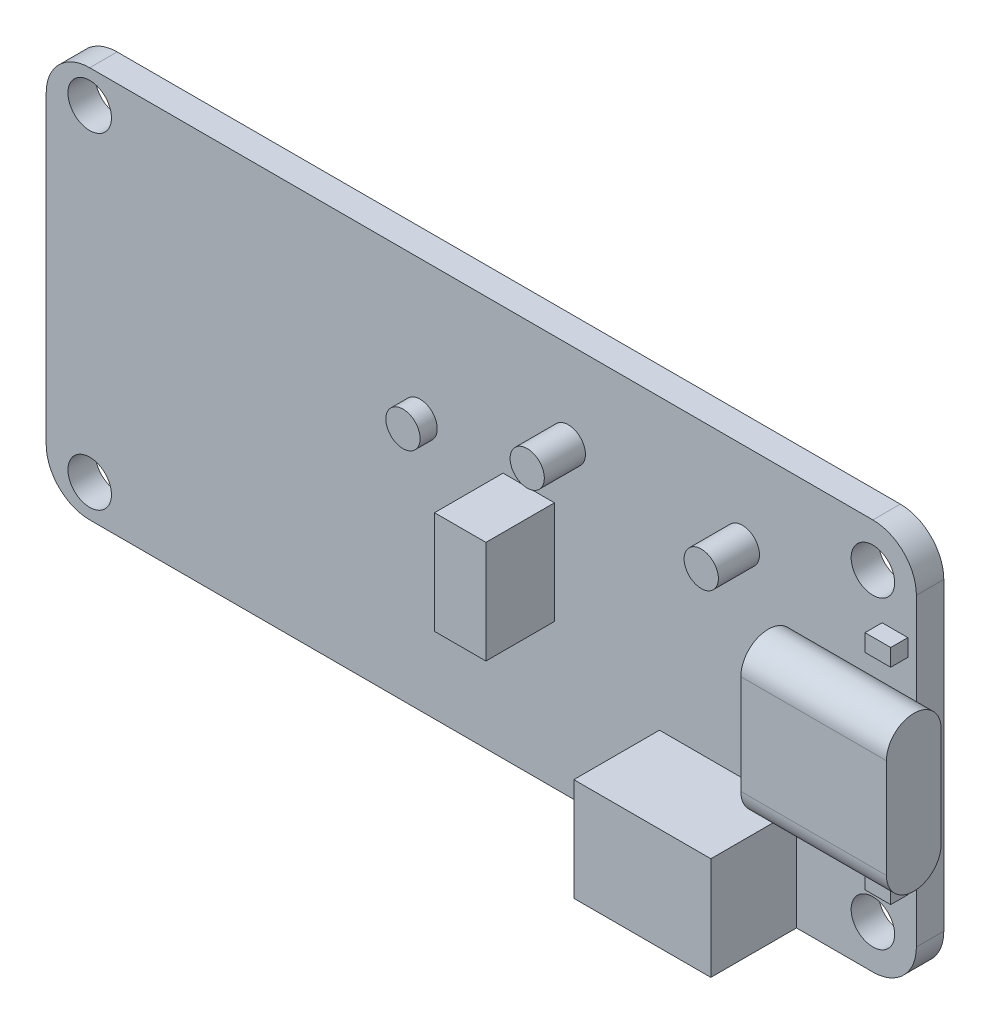
from build123d import *

# Parameters (mm, degrees)
BOARD_DEPTH              = 1.6
DURCHGANGSLOCH_F_R_M21_D = 2.54
USBC_DEPTH               = 1.5
USBC_DEPTH_BACK          = 7
SKIZZE5_W                = 8
SKIZZE5_H                = 5
BATTERY_DEPTH            = 6
SKIZZE6_R                = 1
BUTTONS_DEPTH            = 2.4
SKIZZE7_W                = 3
SKIZZE7_H                = 6
QWIIC_DEPTH              = 4
SKIZZE8_R                = 1
NEOPIXEL_DEPTH           = 1
SKIZZE9_W                = 1.5
SKIZZE9_H                = 1
LEDS_DEPTH               = 1


with BuildPart() as part:
    # Skizze1 → board (new body)
    with BuildSketch(Plane.XY):
        with BuildLine():
            Line((-22.86, -11.43), (22.86, -11.43))
            ThreePointArc((22.86, -11.43), (24.656051224, -10.686051224), (25.4, -8.89))
            Line((25.4, -8.89), (25.4, 8.89))
            ThreePointArc((25.4, 8.89), (24.656051224, 10.686051224), (22.86, 11.43))
            Line((22.86, 11.43), (-22.86, 11.43))
            ThreePointArc((-22.86, 11.43), (-24.656051224, 10.686051224), (-25.4, 8.89))
            Line((-25.4, 8.89), (-25.4, -8.89))
            ThreePointArc((-25.4, -8.89), (-24.656051224, -10.686051224), (-22.86, -11.43))
        make_face()
    extrude(amount=BOARD_DEPTH)

    # Durchgangsloch für M21 (through all)
    with Locations(Plane.XY.offset(1.6)):
        with Locations((-22.86, 9.525), (-22.86, -9.525), (22.86, 8.89), (22.86, -8.89)):
            Hole(DURCHGANGSLOCH_F_R_M21_D / 2)

    # Skizze5 → battery (add)
    with BuildSketch(Plane.XZ.offset(11.43)):
        with Locations((14.4, 4.1)):
            Rectangle(SKIZZE5_W, SKIZZE5_H)
    extrude(amount=-BATTERY_DEPTH)

    # Skizze6 → buttons (add)
    with BuildSketch(Plane.XY.offset(1.6)):
        with Locations((15.24, 6.35)):
            Circle(SKIZZE6_R)
        with Locations((5.08, 6.35)):
            Circle(SKIZZE6_R)
    extrude(amount=BUTTONS_DEPTH)

    # Skizze7 → qwiic (add)
    with BuildSketch(Plane.XY.offset(1.6)):
        with Locations((2.77, 0)):
            Rectangle(SKIZZE7_W, SKIZZE7_H)
    extrude(amount=QWIIC_DEPTH)

    # Skizze8 → neopixel (add)
    with BuildSketch(Plane.XY.offset(1.6)):
        with Locations((-3.572, 3.318)):
            Circle(SKIZZE8_R)
    extrude(amount=NEOPIXEL_DEPTH)

    # Skizze9 → leds (add)
    with BuildSketch(Plane.XY.offset(1.6)):
        with Locations((24.15, 6)):
            Rectangle(SKIZZE9_W, SKIZZE9_H)
        with Locations((24.15, -6)):
            Rectangle(SKIZZE9_W, SKIZZE9_H)
    extrude(amount=LEDS_DEPTH)


with BuildPart() as body_2:
    # Skizze4 → usbc (new body, two sides)
    with BuildSketch(Plane(origin=(25.4, 0, 0), x_dir=(0, 0, -1), z_dir=(1, 0, 0))) as usbc_sk:
        with BuildLine():
            Line((-4.85, -2.9), (-4.85, 2.9))
            ThreePointArc((-4.85, 2.9), (-3.25, 4.5), (-1.65, 2.9))
            Line((-1.65, 2.9), (-1.65, -2.9))
            ThreePointArc((-1.65, -2.9), (-3.25, -4.5), (-4.85, -2.9))
        make_face()
    extrude(amount=USBC_DEPTH)
    extrude(usbc_sk.sketch, amount=-USBC_DEPTH_BACK)


solid = Compound([part.part, body_2.part])
